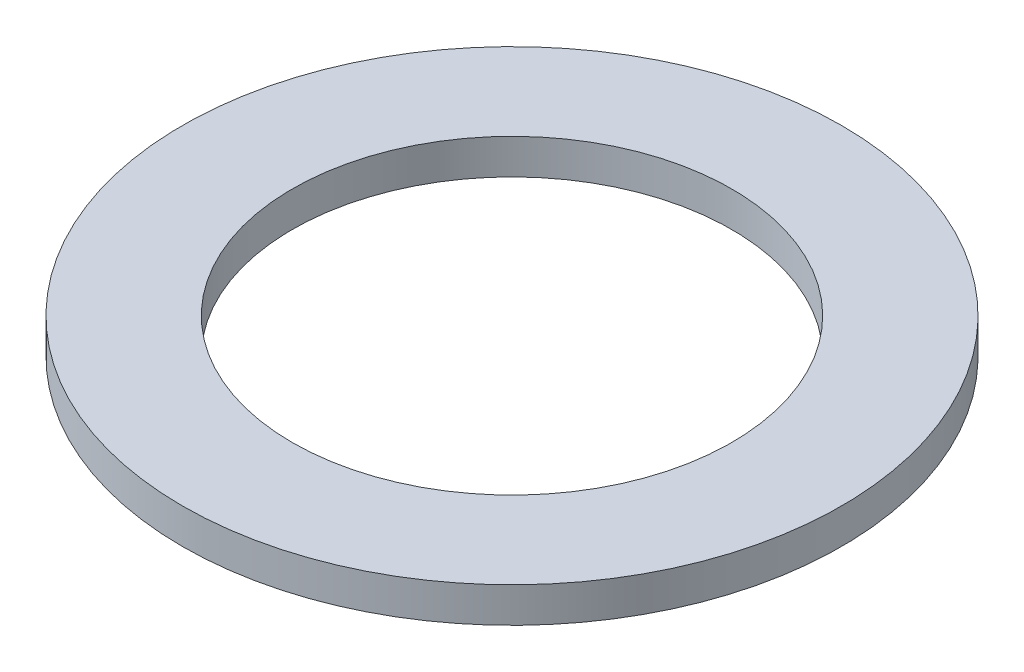
from build123d import *

# Parameters (mm, degrees)
SKETCH1_R           = 9.525
SKETCH1_R_2         = 6.35
BOSS_EXTRUDE1_DEPTH = 1.016


with BuildPart() as part:
    # Sketch1 → Boss-Extrude1 (new body)
    with BuildSketch(Plane(origin=(0, 0, 0), x_dir=(1, 0, 0), z_dir=(0, 1, 0))):
        Circle(SKETCH1_R)
        Circle(SKETCH1_R_2, mode=Mode.SUBTRACT)
    extrude(amount=BOSS_EXTRUDE1_DEPTH)


solid = part.part
